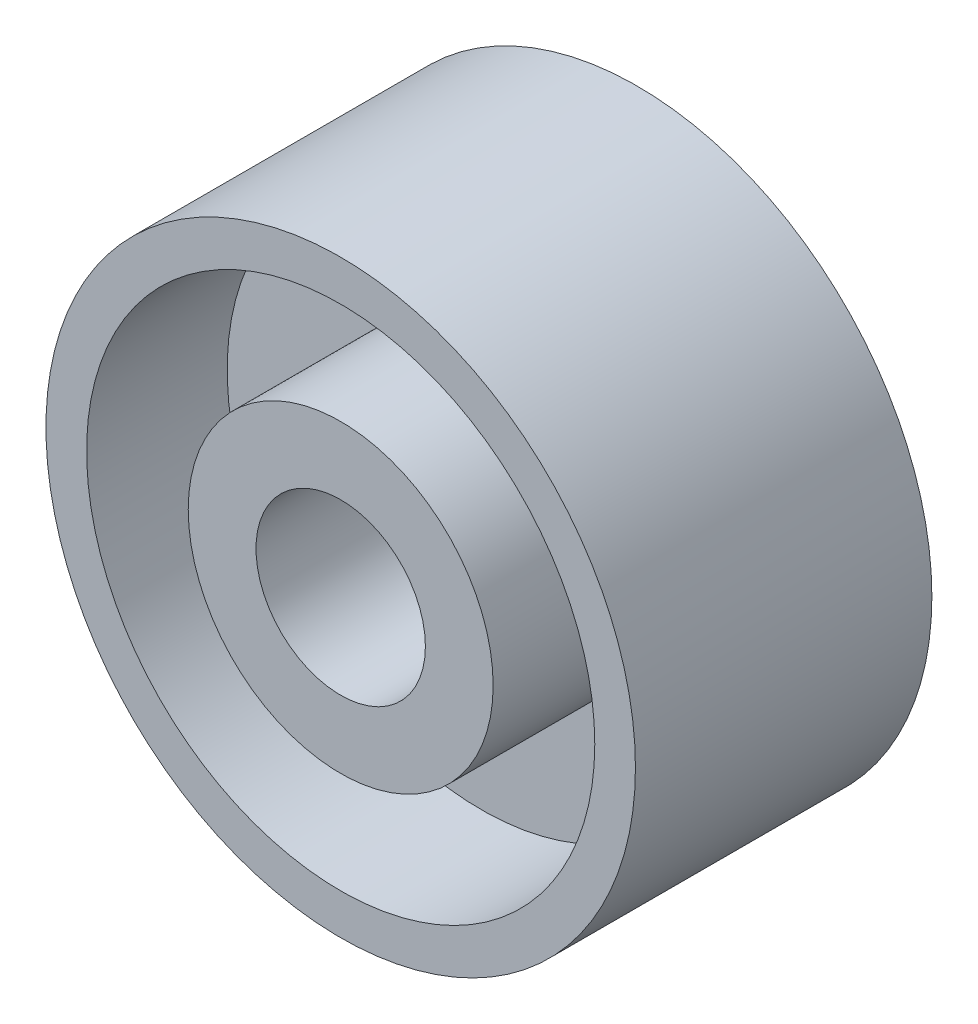
from build123d import *

# Parameters (mm, degrees)
SKETCH1_R           = 1.74
BOSS_EXTRUDE1_DEPTH = 0.875
SKETCH2_R           = 0.5
CUT_EXTRUDE1_DEPTH  = 1.875
SKETCH3_R           = 1.5
SKETCH3_R_2         = 0.9
CUT_EXTRUDE2_DEPTH  = 0.83


with BuildPart() as part:
    # Sketch1 → Boss-Extrude1 (new body)
    with BuildSketch(Plane.XY):
        Circle(SKETCH1_R)
    extrude(amount=-BOSS_EXTRUDE1_DEPTH)

    # Sketch2 → Cut-Extrude1 (cut, through all)
    with BuildSketch(Plane.XY):
        Circle(SKETCH2_R)
    extrude(amount=-CUT_EXTRUDE1_DEPTH, mode=Mode.SUBTRACT)

    # Sketch3 → Cut-Extrude2 (cut)
    with BuildSketch(Plane.XY):
        Circle(SKETCH3_R)
        Circle(SKETCH3_R_2, mode=Mode.SUBTRACT)
    extrude(amount=-CUT_EXTRUDE2_DEPTH, mode=Mode.SUBTRACT)

    # Mirror3: part across plane


with BuildPart() as part_1:
    add(part.part)
    add(part.part.mirror(Plane.XY.offset(-0.875)))


solid = part_1.part
